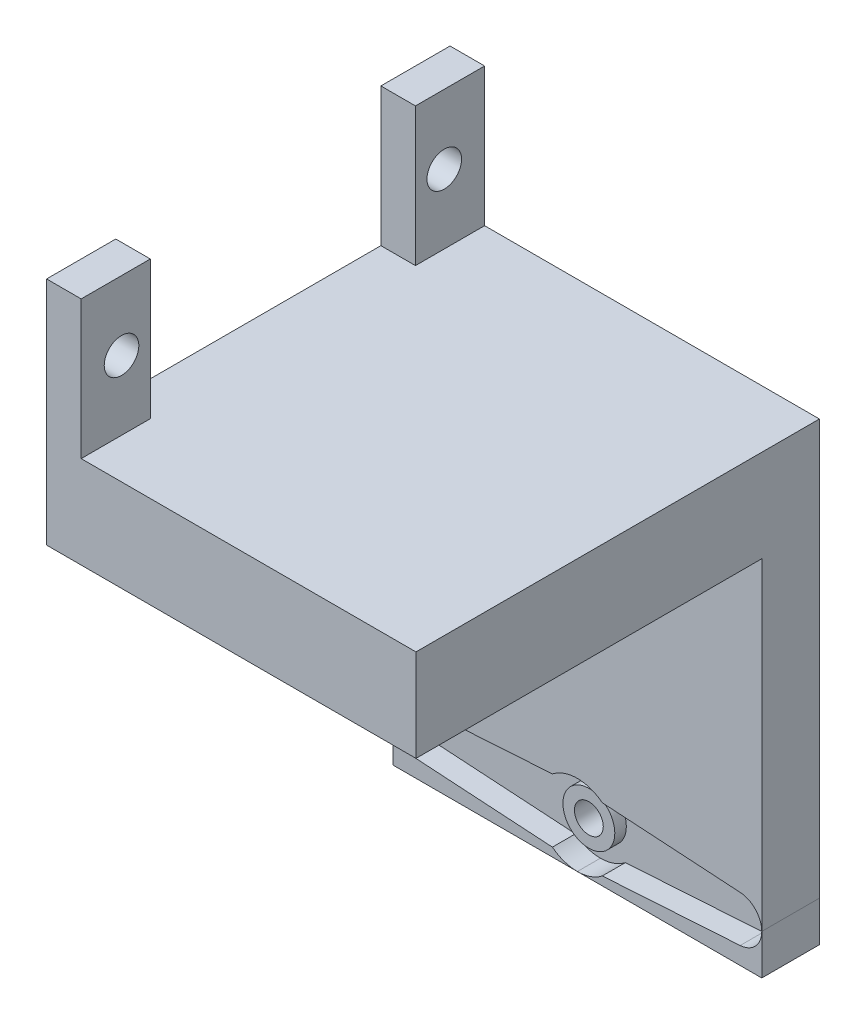
from build123d import *

# Parameters (mm, degrees)
BOSS_EXTRUDE29_DEPTH      = 30
BOSS_EXTRUDE29_DEPTH_BACK = 5
BOSS_EXTRUDE31_DEPTH      = 5
BOSS_EXTRUDE104_START     = -3.5
SKETCH1_23_R              = 2.25
BOSS_EXTRUDE104_DEPTH     = 1.5
BOSS_EXTRUDE105_START     = -1
SKETCH1_24_R              = 2.25
SKETCH1_24_R_2            = 1.25
BOSS_EXTRUDE105_DEPTH     = 2
SKETCH3_W                 = 23
SKETCH3_H                 = 12
CUT_EXTRUDE1_DEPTH        = 66.044949511
SKETCH4_R                 = 1.5
CUT_EXTRUDE2_DEPTH        = 66.044949511


with BuildPart() as part:
    # Sketch1 → Boss-Extrude29 (new, two sides: drawn at the far end of the back side and taken through both)
    with BuildSketch(Plane.XY.offset(-BOSS_EXTRUDE29_DEPTH_BACK)):
        Polygon((-16.034556216, 28), (16, 28), (16, 36), (-13.044429421, 36), (-13.044429421, 48), (-16.044429421, 48), (-16.044429421, 36), align=None)
    extrude(amount=BOSS_EXTRUDE29_DEPTH + BOSS_EXTRUDE29_DEPTH_BACK)

    # Sketch1_12 → Boss-Extrude31 (add)
    with BuildSketch(Plane.XY):
        with BuildLine():
            ThreePointArc((14.125822824, 1.99603823), (15.458020173, 1.369005908), (16, 0))
            Line((16, 0), (16, 28))
            Line((16, 28), (-16.034556216, 28))
            Line((-16.034556216, 28), (-16, 0))
            ThreePointArc((-16, 0), (-15.458020173, 1.369005908), (-14.125822824, 1.99603823))
            Line((-14.125822824, 1.99603823), (-2.165063509, 2.75))
            ThreePointArc((-2.165063509, 2.75), (0, 3.5), (2.165063509, 2.75))
            Line((2.165063509, 2.75), (14.125822824, 1.99603823))
        make_face()
        with BuildLine():
            Line((16, -3.5), (16, 0))
            ThreePointArc((16, 0), (15.458020173, -1.369005908), (14.125822824, -1.99603823))
            Line((14.125822824, -1.99603823), (2.165063509, -2.75))
            ThreePointArc((2.165063509, -2.75), (1.145643924, -3.307189139), (0, -3.5))
            Line((0, -3.5), (16, -3.5))
        make_face()
        with BuildLine():
            Line((-16, -3.5), (0, -3.5))
            ThreePointArc((0, -3.5), (-1.145643924, -3.307189139), (-2.165063509, -2.75))
            Line((-2.165063509, -2.75), (-14.125822824, -1.99603823))
            ThreePointArc((-14.125822824, -1.99603823), (-15.458020173, -1.369005908), (-16, 0))
            Line((-16, 0), (-16, -3.5))
        make_face()
    extrude(amount=-BOSS_EXTRUDE31_DEPTH)


with BuildPart() as boss_extrude31_piece_1:
    # of the separate pieces the step leaves, piece 1, a body of its own (boss_extrude31_pieces)
    add(part.part.solids().sort_by_distance((-16.034556216, 28, 30))[0])

    # Sketch3 → Cut-Extrude1 (cut, through all)
    with BuildSketch(Plane.ZY.offset(16.044429421)):
        with Locations((12.5, 42)):
            Rectangle(SKETCH3_W, SKETCH3_H)
    extrude(amount=-CUT_EXTRUDE1_DEPTH, mode=Mode.SUBTRACT)

    # Sketch4 → Cut-Extrude2 (cut, through all)
    with BuildSketch(Plane.ZY.offset(16.044429421)):
        with Locations((-1.5, 42)):
            Circle(SKETCH4_R)
        with Locations((26.5, 42)):
            Circle(SKETCH4_R)
    extrude(amount=-CUT_EXTRUDE2_DEPTH, mode=Mode.SUBTRACT)


with BuildPart() as boss_extrude31_piece_2:
    # of the separate pieces the step leaves, piece 2, a body of its own (boss_extrude31_pieces)
    add(part.part.solids().sort_by_distance((16, -3.5, 0))[0])


with BuildPart() as boss_extrude31_piece_3:
    # of the separate pieces the step leaves, piece 3, a body of its own (boss_extrude31_pieces)
    add(part.part.solids().sort_by_distance((-16, -3.5, 0))[0])


with BuildPart() as body_4:
    # Sketch1_23 → Boss-Extrude104 (new, symmetric)
    with BuildSketch(Plane.XY.offset(BOSS_EXTRUDE104_START)):
        with BuildLine():
            ThreePointArc((14.125822824, -1.99603823), (16, 0), (14.125822824, 1.99603823))
            Line((14.125822824, 1.99603823), (2.165063509, 2.75))
            ThreePointArc((2.165063509, 2.75), (0, 3.5), (-2.165063509, 2.75))
            Line((-2.165063509, 2.75), (-14.125822824, 1.99603823))
            ThreePointArc((-14.125822824, 1.99603823), (-16, 0), (-14.125822824, -1.99603823))
            Line((-14.125822824, -1.99603823), (-2.165063509, -2.75))
            ThreePointArc((-2.165063509, -2.75), (0, -3.5), (2.165063509, -2.75))
            Line((2.165063509, -2.75), (14.125822824, -1.99603823))
        make_face()
        Circle(SKETCH1_23_R, mode=Mode.SUBTRACT)
    extrude(amount=BOSS_EXTRUDE104_DEPTH, both=True)


with BuildPart() as body_5:
    # Sketch1_24 → Boss-Extrude105 (new body)
    with BuildSketch(Plane.XY.offset(BOSS_EXTRUDE105_START)):
        Circle(SKETCH1_24_R)
        Circle(SKETCH1_24_R_2, mode=Mode.SUBTRACT)
    extrude(amount=-BOSS_EXTRUDE105_DEPTH)


solid = Compound([boss_extrude31_piece_1.part, boss_extrude31_piece_2.part, boss_extrude31_piece_3.part, body_4.part, body_5.part])
